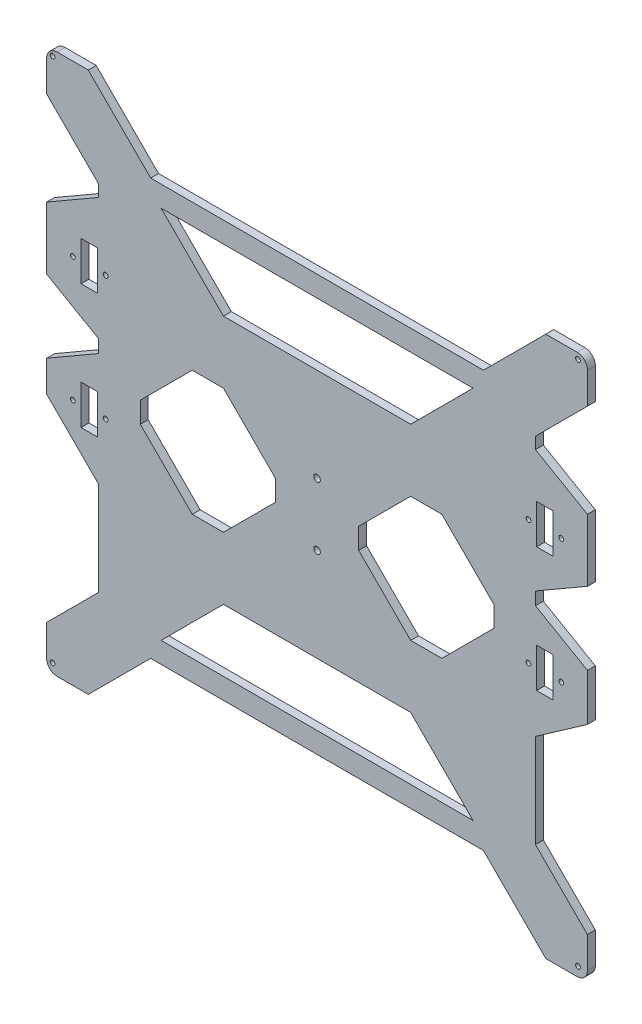
from build123d import *

# Parameters (mm, degrees)
MODEL_R             = 1.4605
MODEL_R_2           = 2
BOSS_EXTRUDE1_DEPTH = 2.413
SKETCH1_W           = 10
SKETCH1_H           = 24
CUT_EXTRUDE1_DEPTH  = 10


with BuildPart() as part:
    # Model → Boss-Extrude1 (new body, symmetric)
    with BuildSketch(Plane.XY):
        with BuildLine():
            Line((-290.681304326, -31.2683), (-258.931304326, -12.937428953))
            Line((-258.931304326, -12.937428953), (-258.931304326, -5.149171047))
            Line((-258.931304326, -5.149171047), (-290.681304326, 13.1817))
            Line((-290.681304326, 13.1817), (-290.681304326, 51.2817))
            Line((-290.681304326, 51.2817), (-258.931304326, 69.612571047))
            Line((-258.931304326, 69.612571047), (-258.931304326, 76.6817))
            Line((-258.931304326, 76.6817), (-290.681304326, 108.4317))
            Line((-290.681304326, 108.4317), (-290.681304326, 127.4817))
            ThreePointArc((-290.681304326, 127.4817), (-288.821432386, 131.971828061), (-284.331304326, 133.8317))
            Line((-284.331304326, 133.8317), (-265.281304326, 133.8317))
            Line((-265.281304326, 133.8317), (-227.181304326, 95.7317))
            Line((-227.181304326, 95.7317), (-23.981304326, 95.7317))
            Line((-23.981304326, 95.7317), (14.118695674, 133.8317))
            Line((14.118695674, 133.8317), (33.168695674, 133.8317))
            ThreePointArc((33.168695674, 133.8317), (37.658823735, 131.971828061), (39.518695674, 127.4817))
            Line((39.518695674, 127.4817), (39.518695674, 108.4317))
            Line((39.518695674, 108.4317), (7.768695674, 76.6817))
            Line((7.768695674, 76.6817), (7.768695674, 69.612571047))
            Line((7.768695674, 69.612571047), (39.518695674, 51.2817))
            Line((39.518695674, 51.2817), (39.518695674, 13.1817))
            Line((39.518695674, 13.1817), (7.768695674, -5.149171047))
            Line((7.768695674, -5.149171047), (7.768695674, -12.937428953))
            Line((7.768695674, -12.937428953), (39.518695674, -31.2683))
            Line((39.518695674, -31.2683), (39.518695674, -59.836710662))
            Line((39.518695674, -59.836710662), (10.464640386, -80.18057919))
            Line((10.464640386, -80.18057919), (7.768695674, -82.0683))
            Line((7.768695674, -82.0683), (7.768695674, -139.2183))
            Line((7.768695674, -139.2183), (39.518695674, -170.9683))
            Line((39.518695674, -170.9683), (39.518695674, -190.0183))
            ThreePointArc((39.518695674, -190.0183), (37.658823735, -194.508428061), (33.168695674, -196.3683))
            Line((33.168695674, -196.3683), (14.118695674, -196.3683))
            Line((14.118695674, -196.3683), (-23.981304326, -158.2683))
            Line((-23.981304326, -158.2683), (-227.181304326, -158.2683))
            Line((-227.181304326, -158.2683), (-265.281304326, -196.3683))
            Line((-265.281304326, -196.3683), (-284.331304326, -196.3683))
            ThreePointArc((-284.331304326, -196.3683), (-288.821432386, -194.508428061), (-290.681304326, -190.0183))
            Line((-290.681304326, -190.0183), (-290.681304326, -170.9683))
            Line((-290.681304326, -170.9683), (-258.931304326, -139.2183))
            Line((-258.931304326, -139.2183), (-258.931304326, -82.0683))
            Line((-258.931304326, -82.0683), (-290.681304326, -50.3183))
            Line((-290.681304326, -50.3183), (-290.681304326, -31.2683))
        make_face()
        with Locations((-287.125304326, -190.6025)):
            Circle(MODEL_R, mode=Mode.SUBTRACT)
        with Locations((33.752895674, -190.6025)):
            Circle(MODEL_R, mode=Mode.SUBTRACT)
        with Locations((33.752895674, 130.2757)):
            Circle(MODEL_R, mode=Mode.SUBTRACT)
        with Locations((-287.125304326, 130.2757)):
            Circle(MODEL_R, mode=Mode.SUBTRACT)
        with Locations((-274.681304256, -45.4288)):
            Circle(MODEL_R, mode=Mode.SUBTRACT)
        with Locations((-254.681304256, -45.4288)):
            Circle(MODEL_R, mode=Mode.SUBTRACT)
        with Locations((23.518695604, -45.4288)):
            Circle(MODEL_R, mode=Mode.SUBTRACT)
        with Locations((3.518695604, -45.4288)):
            Circle(MODEL_R, mode=Mode.SUBTRACT)
        with Locations((23.518695604, 30.5682)):
            Circle(MODEL_R, mode=Mode.SUBTRACT)
        with Locations((3.518695604, 30.5682)):
            Circle(MODEL_R, mode=Mode.SUBTRACT)
        with Locations((-254.681304256, 30.5682)):
            Circle(MODEL_R, mode=Mode.SUBTRACT)
        with Locations((-274.681304256, 30.5682)):
            Circle(MODEL_R, mode=Mode.SUBTRACT)
        with Locations((-125.581304326, -12.2183)):
            Circle(MODEL_R_2, mode=Mode.SUBTRACT)
        with Locations((-125.581304326, -50.3183)):
            Circle(MODEL_R_2, mode=Mode.SUBTRACT)
        Polygon((-30.331304326, -145.5683), (-68.431304326, -107.4683), (-182.731304326, -107.4683), (-220.831304326, -145.5683), align=None, mode=Mode.SUBTRACT)
        Polygon((-220.831304326, 83.0317), (-182.731304326, 44.9317), (-68.431304326, 44.9317), (-30.331304326, 83.0317), align=None, mode=Mode.SUBTRACT)
        Polygon((-201.781304326, -69.3683), (-233.531304326, -37.6183), (-233.531304326, -24.9183), (-201.781304326, 6.8317), (-182.731304326, 6.8317), (-150.981304326, -24.9183), (-150.981304326, -37.6183), (-182.731304326, -69.3683), align=None, mode=Mode.SUBTRACT)
        Polygon((-100.181304326, -37.6183), (-100.181304326, -24.9183), (-68.431304326, 6.8317), (-49.381304326, 6.8317), (-17.631304326, -24.9183), (-17.631304326, -37.6183), (-49.381304326, -69.3683), (-68.431304326, -69.3683), align=None, mode=Mode.SUBTRACT)
    extrude(amount=BOSS_EXTRUDE1_DEPTH, both=True)

    # Sketch1 → Cut-Extrude1 (cut)
    with BuildSketch(Plane.XY.offset(2.413)):
        with Locations((-264.681304256, -45.4288)):
            Rectangle(SKETCH1_W, SKETCH1_H)
        with Locations((-264.681304256, 30.5712)):
            Rectangle(SKETCH1_W, SKETCH1_H)
        with Locations((13.518695604, 30.5712)):
            Rectangle(SKETCH1_W, SKETCH1_H)
        with Locations((13.518695604, -45.4288)):
            Rectangle(SKETCH1_W, SKETCH1_H)
    extrude(amount=-CUT_EXTRUDE1_DEPTH, mode=Mode.SUBTRACT)


solid = part.part
